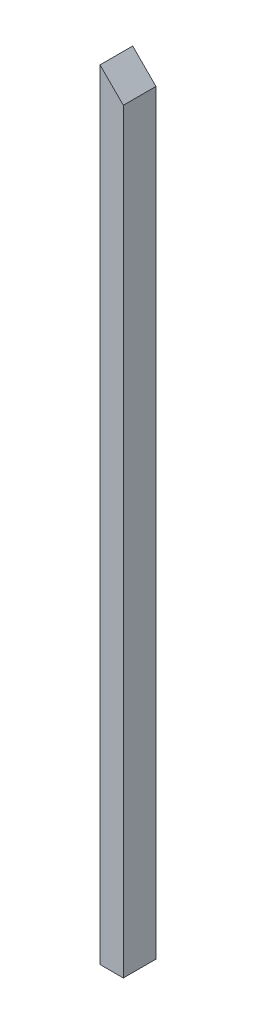
from build123d import *

# Parameters (mm, degrees)
BOSS_EXTRUDE1_DEPTH = 88.9


with BuildPart() as part:
    # Sketch1 → Boss-Extrude1 (new body)
    with BuildSketch(Plane.XY):
        Polygon((0, 0), (0, 2120.9), (63.5, 2057.4), (63.5, 0), align=None)
    extrude(amount=BOSS_EXTRUDE1_DEPTH)


solid = part.part
